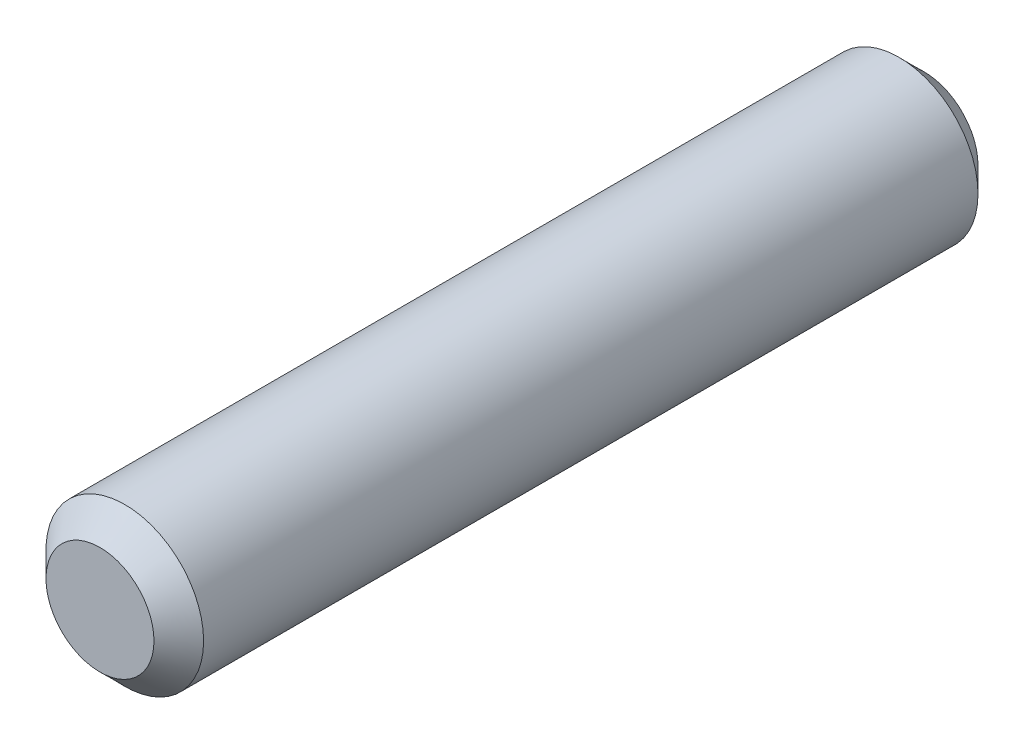
from build123d import *

# Parameters (mm, degrees)
SKETCH1_R           = 3.175
BOSS_EXTRUDE1_DEPTH = 33.2
CHAMFER1_SIZE       = 1


with BuildPart() as part:
    # Sketch1 → Boss-Extrude1 (new body)
    with BuildSketch(Plane.XY):
        Circle(SKETCH1_R)
    extrude(amount=BOSS_EXTRUDE1_DEPTH)

    # Chamfer1
    chamfer1_edges = [part.edges().sort_by_distance(p)[0] for p in [
        (-3.175, 0, 0),
        (-3.175, 0, 33.2),
    ]]
    chamfer(chamfer1_edges, length=CHAMFER1_SIZE)


solid = part.part
